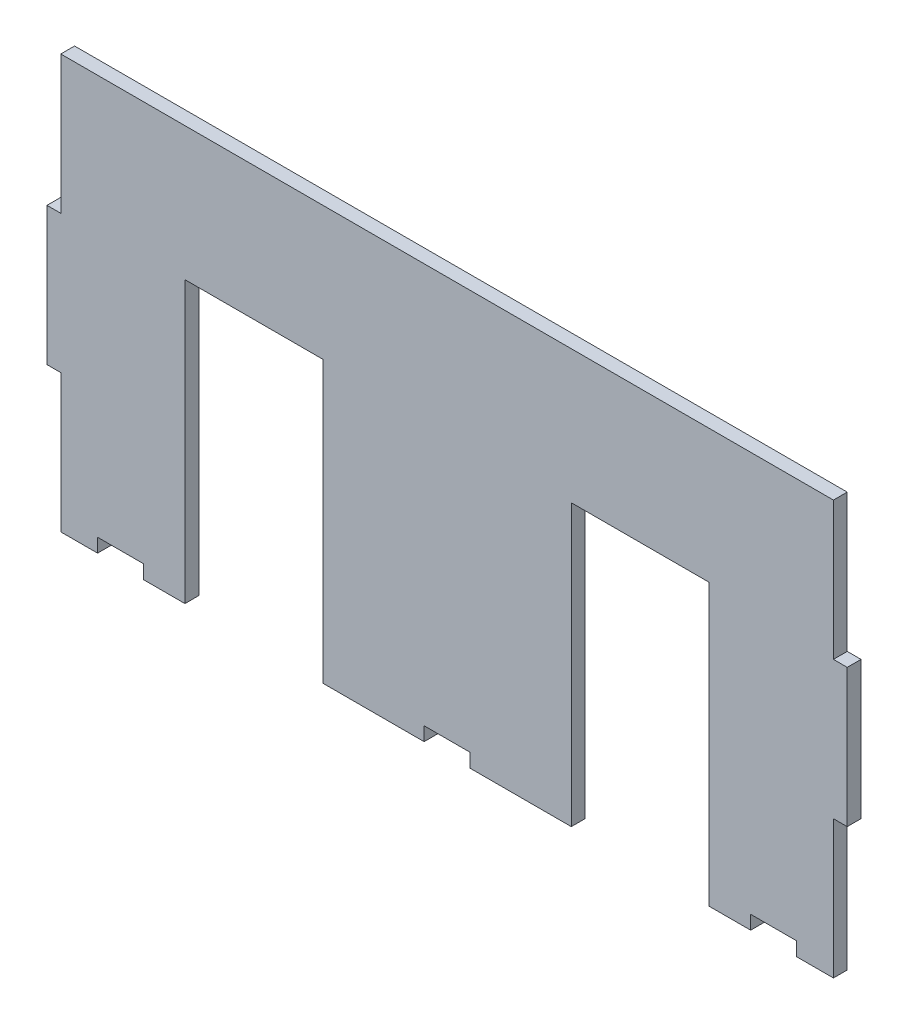
from build123d import *

# Parameters (mm, degrees)
BOSS_EXTRUDE1_DEPTH = 3


with BuildPart() as part:
    # Model → Boss-Extrude1 (new body)
    with BuildSketch(Plane.XY):
        Polygon((178.190497344, 199.123752973), (178.190497344, 169.123752973), (181.190497344, 169.123752973), (181.190497344, 139.123752973), (189.190497344, 139.123752973), (189.190497344, 142.123752973), (199.190497344, 142.123752973), (199.190497344, 139.123752973), (208.190497344, 139.123752973), (208.190497344, 200.123752973), (238.190497344, 200.123752973), (238.190497344, 139.123752973), (260.190497344, 139.123752973), (260.190497344, 142.123752973), (270.190497344, 142.123752973), (270.190497344, 139.123752973), (292.190497344, 139.123752973), (292.190497344, 200.123752973), (322.190497344, 200.123752973), (322.190497344, 139.123752973), (331.190497344, 139.123752973), (331.190497344, 142.123752973), (341.190497344, 142.123752973), (341.190497344, 139.123752973), (349.190497344, 139.123752973), (349.190497344, 169.123752973), (352.190497344, 169.123752973), (352.190497344, 199.123752973), (349.190497344, 199.123752973), (349.190497344, 229.123752973), (181.190497344, 229.123752973), (181.190497344, 199.123752973), align=None)
    extrude(amount=BOSS_EXTRUDE1_DEPTH)


solid = part.part
